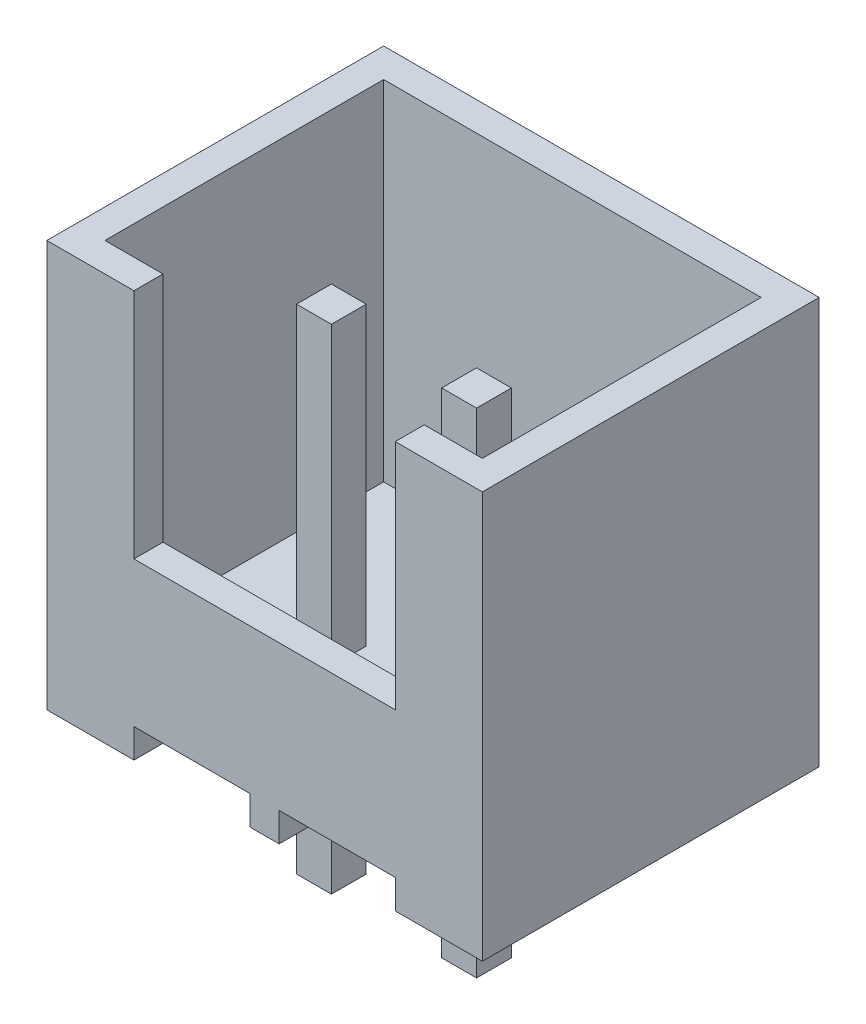
from build123d import *

# Parameters (mm, degrees)
EXTRUDE_1_DEPTH      = 5.8
SKETCH_2_W           = 6.5
SKETCH_2_H           = 4.8
CUT_EXTRUDE_1_DEPTH  = 6
SKETCH_3_W           = 0.6
SKETCH_3_H           = 0.6
EXTRUDE_2_DEPTH      = 2.4
EXTRUDE_2_DEPTH_BACK = 6.1
SKETCH_5_W           = 4.5
SKETCH_5_H           = 4
CUT_EXTRUDE_2_DEPTH  = 1


with BuildPart() as part:
    # 草图1 → 凸台-拉伸1 (new body)
    with BuildSketch(Plane.XY):
        Polygon((1.5, 0), (1.5, 0.5), (3.5, 0.5), (3.5, 0), (4, 0), (4, 0.5), (6, 0.5), (6, 0), (7.5, 0), (7.5, 7), (0, 7), (0, 0), align=None)
    extrude(amount=EXTRUDE_1_DEPTH)

    # 草图2 → 切除-拉伸1 (cut)
    with BuildSketch(Plane(origin=(0, 7, 0), x_dir=(1, 0, 0), z_dir=(0, 1, 0))):
        with Locations((3.75, -2.9)):
            Rectangle(SKETCH_2_W, SKETCH_2_H)
    extrude(amount=-CUT_EXTRUDE_1_DEPTH, mode=Mode.SUBTRACT)

    # 草图3 → 凸台-拉伸2 (add, two sides)
    with BuildSketch(Plane.XZ) as extrude_2_sk:
        with Locations((2.5, 3.4)):
            Rectangle(SKETCH_3_W, SKETCH_3_H)
        with Locations((5, 3.4)):
            Rectangle(SKETCH_3_W, SKETCH_3_H)
    extrude(amount=EXTRUDE_2_DEPTH)
    extrude(extrude_2_sk.sketch, amount=-EXTRUDE_2_DEPTH_BACK)

    # 草图5 → 切除-拉伸2 (cut)
    with BuildSketch(Plane.XY.offset(5.8)):
        with Locations((3.75, 5)):
            Rectangle(SKETCH_5_W, SKETCH_5_H)
    extrude(amount=-CUT_EXTRUDE_2_DEPTH, mode=Mode.SUBTRACT)


solid = part.part
